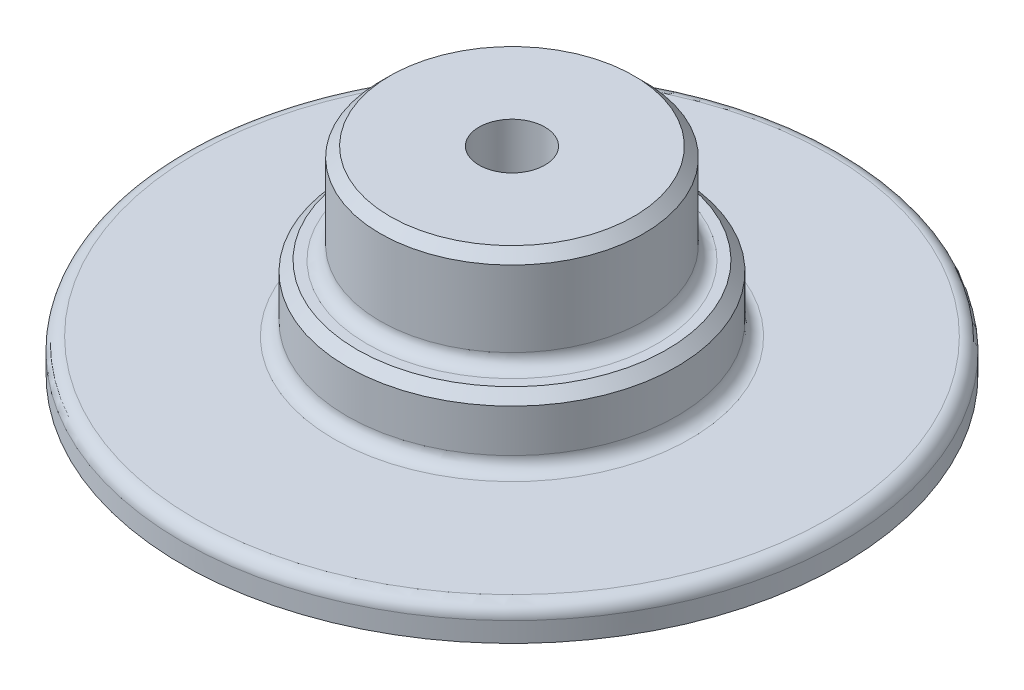
from build123d import *

# Parameters (mm, degrees)
FILLET4_R     = 8
CHAMFER5_SIZE = 6
FILLET5_R     = 8


with BuildPart() as part:
    # Sketch1 → Revolve5 (revolve)
    with BuildSketch(Plane.XY):
        Polygon((180, 0), (0, 0), (0, 120), (60, 120), (60, 60), (80, 60), (80, 20), (180, 20), align=None)
    revolve(axis=Axis((-20, 0, 0), (0, 1, 0)))

    # Fillet4
    fillet4_edges = [part.edges().sort_by_distance(p)[0] for p in [
        (-220, 20, 0),
    ]]
    fillet(fillet4_edges, radius=FILLET4_R)

    # Chamfer5
    chamfer5_edges = [part.edges().sort_by_distance(p)[0] for p in [
        (-120, 60, 0),
        (-100, 120, 0),
    ]]
    chamfer(chamfer5_edges, length=CHAMFER5_SIZE)

    # Fillet5
    fillet5_edges = [part.edges().sort_by_distance(p)[0] for p in [
        (-120, 20, 0),
        (-100, 60, 0),
    ]]
    fillet(fillet5_edges, radius=FILLET5_R)


solid = part.part
